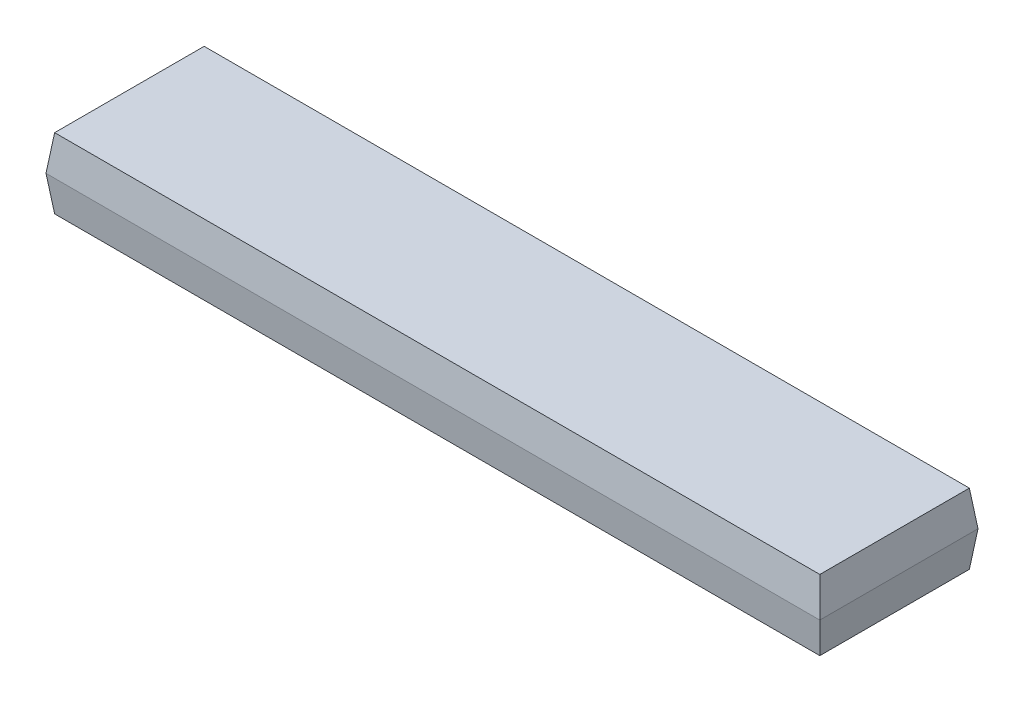
from build123d import *

# Parameters (mm, degrees)
ESQUISSE1_W        = 34.8
ESQUISSE1_H        = 6.8
BOSS_EXTRU_1_DEPTH = 1.6
BOSS_EXTRU_1_TAPER = -7
ESQUISSE2_W        = 35.192910594
ESQUISSE2_H        = 7.192910594
BOSS_EXTRU_2_DEPTH = 1.6
BOSS_EXTRU_2_TAPER = 7


with BuildPart() as part:
    # Esquisse1 → Boss.-Extru.1 (new body)
    with BuildSketch(Plane(origin=(0, 0, 0), x_dir=(1, 0, 0), z_dir=(0, 1, 0))):
        with Locations((17.4, 3.4)):
            Rectangle(ESQUISSE1_W, ESQUISSE1_H)
    extrude(amount=BOSS_EXTRU_1_DEPTH, taper=BOSS_EXTRU_1_TAPER)

    # Esquisse2 → Boss.-Extru.2 (add)
    with BuildSketch(Plane(origin=(0, 1.6, 0), x_dir=(1, 0, 0), z_dir=(0, 1, 0))):
        with Locations((17.4, 3.4)):
            Rectangle(ESQUISSE2_W, ESQUISSE2_H)
    extrude(amount=BOSS_EXTRU_2_DEPTH, taper=BOSS_EXTRU_2_TAPER)


solid = part.part
